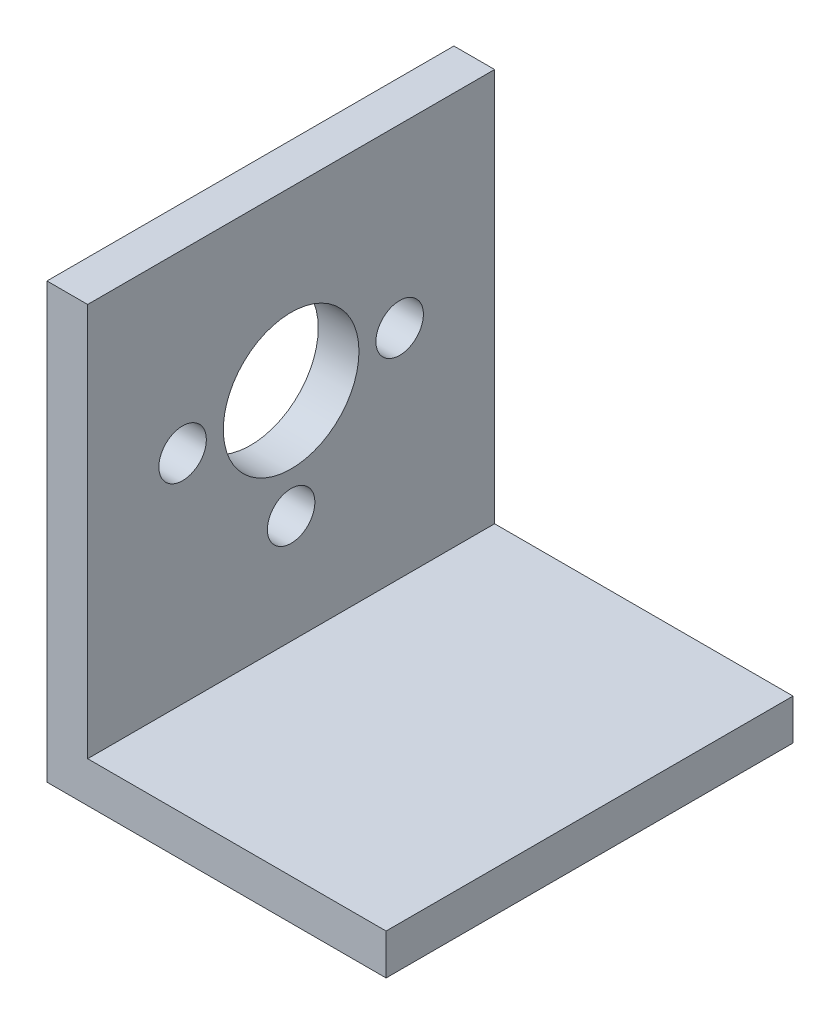
from build123d import *

# Parameters (mm, degrees)
BOSS_EXTRUDE1_DEPTH            = 30
HOLE_FOR_M5_300_SC_NUTS_SP_1_D = 10
HOLE_FOR_M5_300_SC_NUTS_SP_2_D = 3.5


with BuildPart() as part:
    # Sketch1 → Boss-Extrude1 (new body)
    with BuildSketch(Plane.XY):
        Polygon((-7.897485035, 31.347562808), (-7.897485035, 2.347562808), (14.102514965, 2.347562808), (14.102514965, -0.652437192), (-10.897485035, -0.652437192), (-10.897485035, 31.347562808), align=None)
    extrude(amount=BOSS_EXTRUDE1_DEPTH)

    # Hole for M5 300® SC Nuts (SP)1 (through all)
    with Locations(Plane(origin=(-7.897485035, 0, 0), x_dir=(0, 0, -1), z_dir=(1, 0, 0))):
        with Locations((-15, 18.347562808)):
            Hole(HOLE_FOR_M5_300_SC_NUTS_SP_1_D / 2)

    # Hole for M5 300® SC Nuts (SP)2 (through all)
    with Locations(Plane(origin=(-7.897485035, 0, 0), x_dir=(0, 0, -1), z_dir=(1, 0, 0))):
        with Locations((-7, 18.347562808), (-23, 18.347562808), (-15, 10.347562808)):
            Hole(HOLE_FOR_M5_300_SC_NUTS_SP_2_D / 2)


solid = part.part
